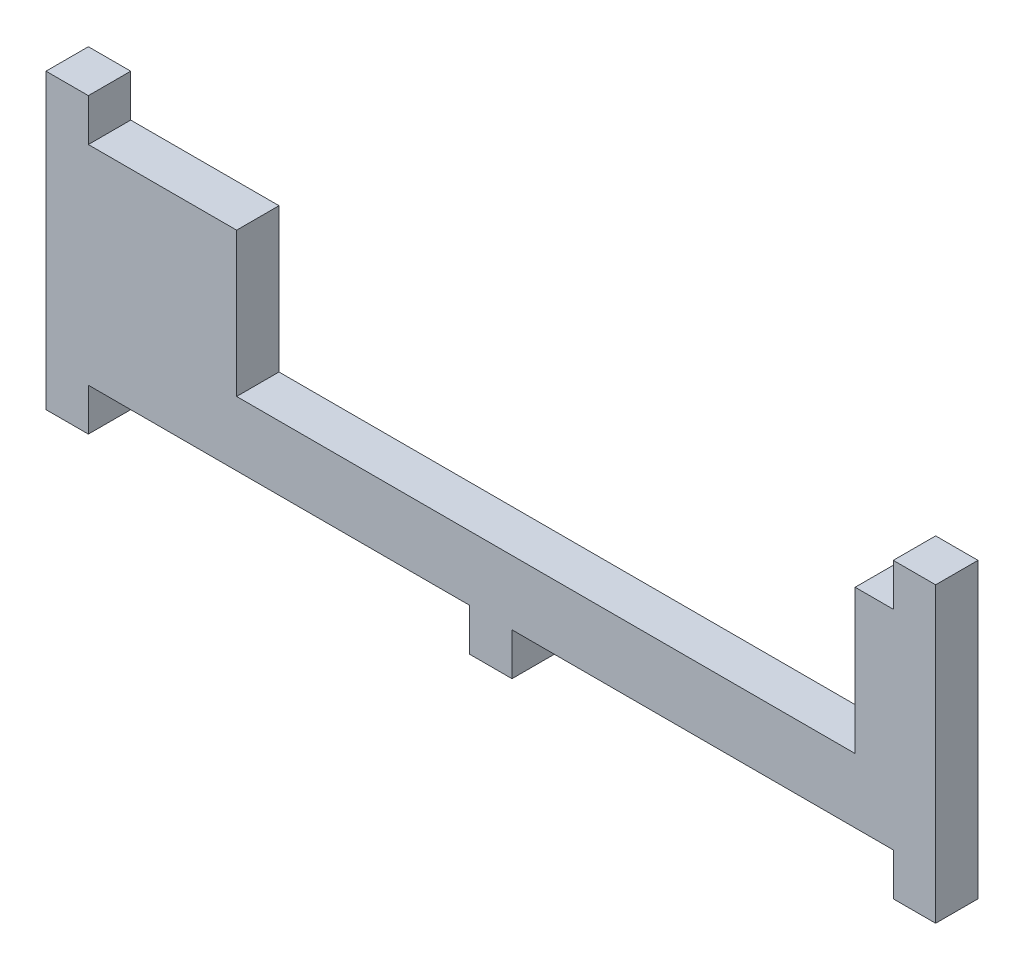
from build123d import *

# Parameters (mm, degrees)
SKETCH1_W           = 105
SKETCH1_H           = 12.3
BOSS_EXTRUDE1_DEPTH = 5
SKETCH2_W           = 5
SKETCH2_H           = 5
BOSS_EXTRUDE2_DEPTH = 5
SKETCH3_W           = 73
SKETCH3_H           = 5
CUT_EXTRUDE1_DEPTH  = 17
SKETCH4_W           = 5
SKETCH4_H           = 5
BOSS_EXTRUDE3_DEPTH = 5


with BuildPart() as part:
    # Sketch1 → Boss-Extrude1 (new body)
    with BuildSketch(Plane.XY):
        Rectangle(SKETCH1_W, SKETCH1_H)
    extrude(amount=BOSS_EXTRUDE1_DEPTH)

    # Sketch2 → Boss-Extrude2 (add)
    with BuildSketch(Plane.XZ.offset(6.15)):
        with Locations((-50, 2.5)):
            Rectangle(SKETCH2_W, SKETCH2_H)
        with Locations((50, 2.5)):
            Rectangle(SKETCH2_W, SKETCH2_H)
    extrude(amount=BOSS_EXTRUDE2_DEPTH)

    # Mirror1: part across plane


with BuildPart() as part_1:
    add(part.part)
    add(part.part.mirror(Plane(origin=(-52.5, 6.15, 5), x_dir=(0, 0, 1), z_dir=(0, -1, 0))))

    # Sketch3 → Cut-Extrude1 (cut)
    with BuildSketch(Plane(origin=(0, 18.45, 0), x_dir=(1, 0, 0), z_dir=(0, 1, 0))):
        with Locations((6.5, -2.5)):
            Rectangle(SKETCH3_W, SKETCH3_H)
    extrude(amount=-CUT_EXTRUDE1_DEPTH, mode=Mode.SUBTRACT)

    # Sketch4 → Boss-Extrude3 (add)
    with BuildSketch(Plane.XZ.offset(6.15)):
        with Locations((0, 2.5)):
            Rectangle(SKETCH4_W, SKETCH4_H)
    extrude(amount=BOSS_EXTRUDE3_DEPTH)


solid = part_1.part
